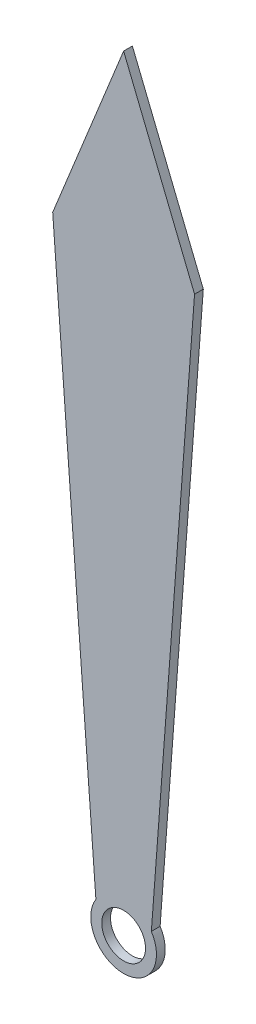
from build123d import *

# Parameters (mm, degrees)
CROQUIS1_R              = 0.5
SALIENTE_EXTRUIR2_DEPTH = 0.2


with BuildPart() as part:
    # Croquis1 → Saliente-Extruir2 (new body)
    with BuildSketch(Plane.XY):
        with BuildLine():
            Line((-1.620168748, 13.5), (-0.633616905, 0.401284958))
            ThreePointArc((-0.633616905, 0.401284958), (0, -0.75), (0.633616905, 0.401284958))
            Line((0.633616905, 0.401284958), (1.620168748, 13.5))
            Line((1.620168748, 13.5), (0, 17.5))
            Line((0, 17.5), (-1.620168748, 13.5))
        make_face()
        Circle(CROQUIS1_R, mode=Mode.SUBTRACT)
    extrude(amount=SALIENTE_EXTRUIR2_DEPTH)


solid = part.part
